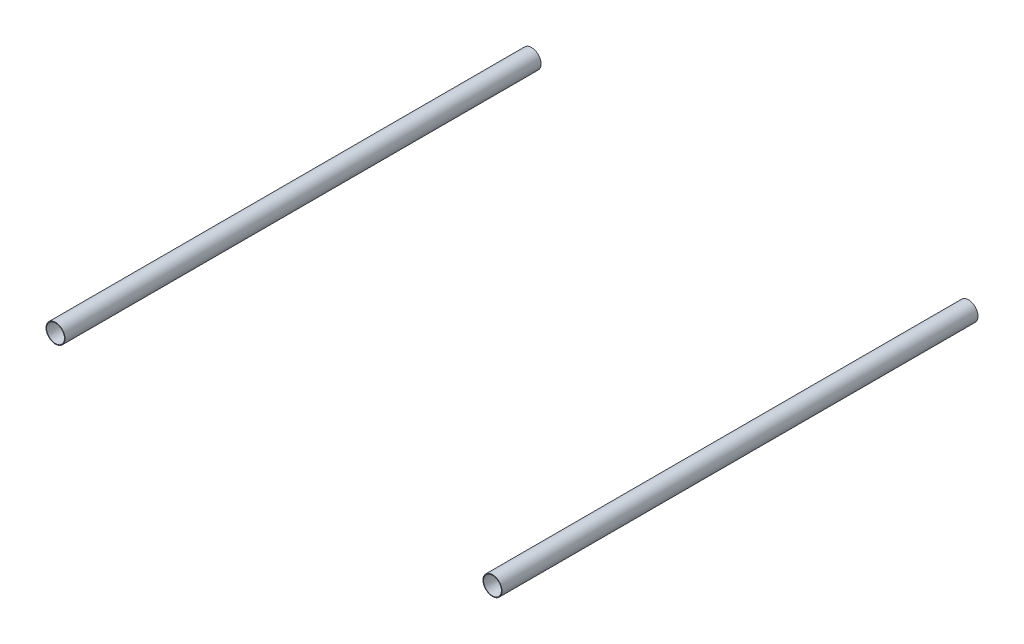
from build123d import *

# Parameters (mm, degrees)
SKETCH1_R             = 50
SKETCH1_R_2           = 47
EXTRUDE_THIN1_DEPTH   = 2500
EXTRUDE_THIN1_2_DEPTH = 2500


with BuildPart() as part:
    # Sketch1 → Extrude-Thin1 (new body)
    with BuildSketch(Plane.XY):
        Circle(SKETCH1_R)
        Circle(SKETCH1_R_2, mode=Mode.SUBTRACT)
    extrude(amount=EXTRUDE_THIN1_DEPTH)


with BuildPart() as body_2:
    # Sketch1 → Extrude-Thin1 2 (new body)
    with BuildSketch(Plane.XY):
        with Locations((-2295, 0)):
            Circle(SKETCH1_R)
        with Locations((-2295, 0)):
            Circle(SKETCH1_R_2, mode=Mode.SUBTRACT)
    extrude(amount=EXTRUDE_THIN1_2_DEPTH)


solid = Compound([part.part, body_2.part])
